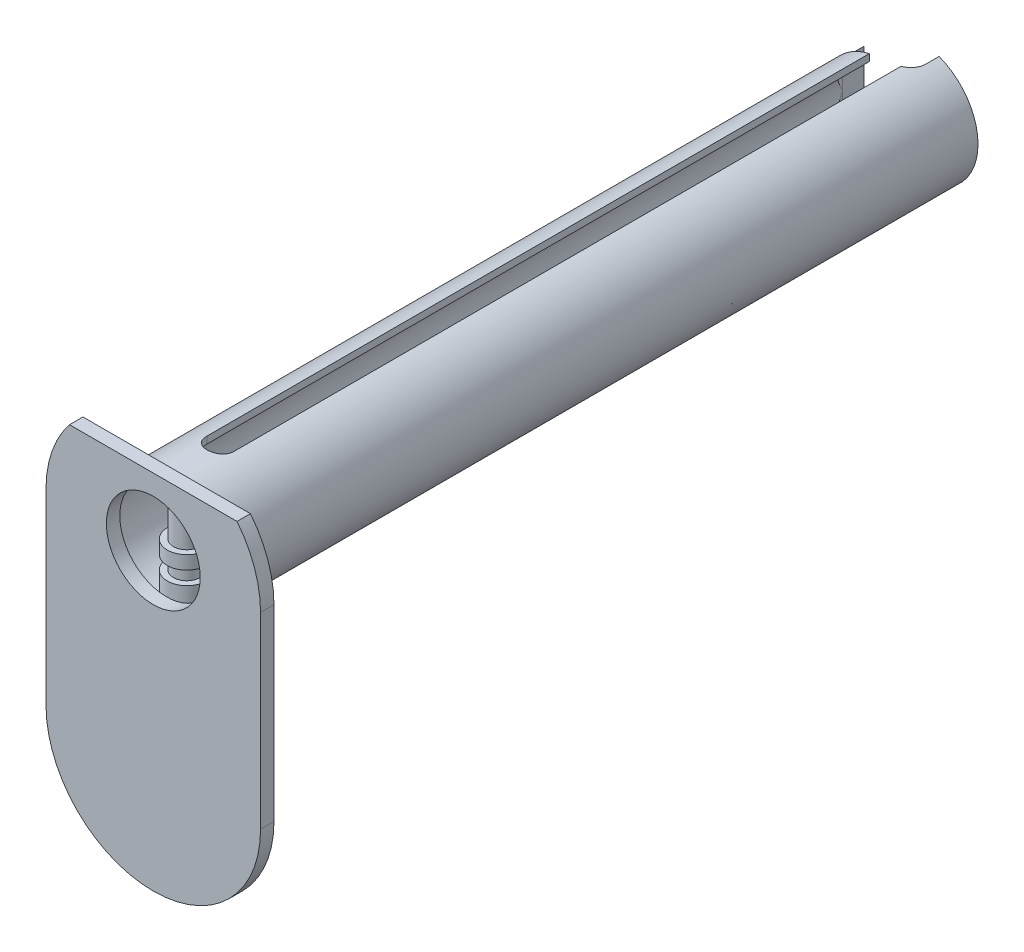
from build123d import *

# Parameters (mm, degrees)
ESQUISSE1_R                    = 4.5
ESQUISSE1_R_2                  = 4
BOSS_EXTRU_1_DEPTH             = 28
BOSS_EXTRU_2_REACH             = 6.5
ESQUISSE2_R                    = 1
ESQUISSE2_R_2                  = 0.5
BOSS_EXTRU_2_DIRECTION_2_REACH = 6.5
ENL_V_MAT_EXTRU_1_DEPTH        = 5.5
ENL_V_MAT_EXTRU_1_DEPTH_BACK   = 5.5
ESQUISSE4_R                    = 3.5
BOSS_EXTRU_3_DEPTH             = 1
ESQUISSE6_OUTSIDE_W            = 31.274
ESQUISSE6_OUTSIDE_H            = 45.274
ESQUISSE6_OUTSIDE_W_2          = 16
ESQUISSE6_OUTSIDE_H_2          = 27
ENL_V_MAT_EXTRU_2_DEPTH        = 58.0000001
BOSS_EXTRU_6_START             = -1.5
ESQUISSE7_R                    = 1.45
BOSS_EXTRU_6_DEPTH             = 1
BOSS_EXTRU_7_REACH             = 23.5
BOSS_EXTRU_7_START             = 1
ESQUISSE8_R                    = 1.45
ENL_V_MAT_EXTRU_3_DEPTH        = 6
ENL_V_MAT_EXTRU_3_DEPTH_BACK   = 23


with BuildPart() as part:
    # Esquisse1 → Boss.-Extru.1 (new body, symmetric)
    with BuildSketch(Plane.XY):
        Circle(ESQUISSE1_R)
        Circle(ESQUISSE1_R_2, mode=Mode.SUBTRACT)
    extrude(amount=BOSS_EXTRU_1_DEPTH, both=True)

    # Esquisse2 → Boss.-Extru.2 (add, up to next)
    with BuildSketch(Plane(origin=(0, 0, 0), x_dir=(1, 0, 0), z_dir=(0, 1, 0)), mode=Mode.PRIVATE) as boss_extru_2_sk1:
        with Locations((0, -26.5)):
            Circle(ESQUISSE2_R)
    boss_extru_2_tool1 = extrude(boss_extru_2_sk1.sketch, amount=BOSS_EXTRU_2_REACH, mode=Mode.PRIVATE) - part.part
    add(boss_extru_2_tool1.solids().sort_by_distance((0, 0, 26.5))[0])
    # Esquisse2 → Boss.-Extru.2 (add, up to next)
    with BuildSketch(Plane(origin=(0, 0, 0), x_dir=(1, 0, 0), z_dir=(0, 1, 0)), mode=Mode.PRIVATE) as boss_extru_2_sk2:
        with Locations((3, 26.5)):
            Circle(ESQUISSE2_R_2)
    boss_extru_2_tool2 = extrude(boss_extru_2_sk2.sketch, amount=BOSS_EXTRU_2_REACH, mode=Mode.PRIVATE) - part.part
    add(boss_extru_2_tool2.solids().sort_by_distance((3, 0, -26.5))[0])

    # Esquisse2 → Boss.-Extru.2 direction 2 (add, up to next)
    with BuildSketch(Plane(origin=(0, 0, 0), x_dir=(1, 0, 0), z_dir=(0, 1, 0)), mode=Mode.PRIVATE) as boss_extru_2_direction_2_sk1:
        with Locations((0, -26.5)):
            Circle(ESQUISSE2_R)
    boss_extru_2_direction_2_tool1 = extrude(boss_extru_2_direction_2_sk1.sketch, amount=-BOSS_EXTRU_2_DIRECTION_2_REACH, mode=Mode.PRIVATE) - part.part
    add(boss_extru_2_direction_2_tool1.solids().sort_by_distance((0, 0, 26.5))[0])
    # Esquisse2 → Boss.-Extru.2 direction 2 (add, up to next)
    with BuildSketch(Plane(origin=(0, 0, 0), x_dir=(1, 0, 0), z_dir=(0, 1, 0)), mode=Mode.PRIVATE) as boss_extru_2_direction_2_sk2:
        with Locations((3, 26.5)):
            Circle(ESQUISSE2_R_2)
    boss_extru_2_direction_2_tool2 = extrude(boss_extru_2_direction_2_sk2.sketch, amount=-BOSS_EXTRU_2_DIRECTION_2_REACH, mode=Mode.PRIVATE) - part.part
    add(boss_extru_2_direction_2_tool2.solids().sort_by_distance((3, 0, -26.5))[0])

    # Esquisse3 → Enlèv. mat.-Extru.1 (cut, two sides)
    with BuildSketch(Plane(origin=(0, 0, 0), x_dir=(1, 0, 0), z_dir=(0, 1, 0))) as enl_v_mat_extru_1_sk:
        with BuildLine():
            Line((1, 28), (1, -24))
            ThreePointArc((1, -24), (0, -25), (-1, -24))
            Line((-1, -24), (-1, 28))
            ThreePointArc((-1, 28), (0, 29), (1, 28))
        make_face()
    extrude(amount=ENL_V_MAT_EXTRU_1_DEPTH, mode=Mode.SUBTRACT)
    extrude(enl_v_mat_extru_1_sk.sketch, amount=-ENL_V_MAT_EXTRU_1_DEPTH_BACK, mode=Mode.SUBTRACT)

    # Esquisse4 → Boss.-Extru.3 (add)
    with BuildSketch(Plane.XY.offset(28)):
        with BuildLine():
            Line((8, 0), (8, -14))
            ThreePointArc((8, -14), (0, -22), (-8, -14))
            Line((-8, -14), (-8, 0))
            ThreePointArc((-8, 0), (0, 8), (8, 0))
        make_face()
        Circle(ESQUISSE4_R, mode=Mode.SUBTRACT)
    extrude(amount=BOSS_EXTRU_3_DEPTH)

    # Esquisse6 outside → Enlèv. mat.-Extru.2 (cut, through all)
    with BuildSketch(Plane.XY.offset(29)):
        with Locations((0, -7)):
            Rectangle(ESQUISSE6_OUTSIDE_W, ESQUISSE6_OUTSIDE_H)
        with Locations((0, -8.5)):
            Rectangle(ESQUISSE6_OUTSIDE_W_2, ESQUISSE6_OUTSIDE_H_2, mode=Mode.SUBTRACT)
    extrude(amount=-ENL_V_MAT_EXTRU_2_DEPTH, mode=Mode.SUBTRACT)

    # Esquisse7 → Boss.-Extru.6 (add)
    with BuildSketch(Plane(origin=(0, 0, 0), x_dir=(1, 0, 0), z_dir=(0, 1, 0)).offset(BOSS_EXTRU_6_START)):
        with Locations((0, -26.5)):
            Circle(ESQUISSE7_R)
    extrude(amount=BOSS_EXTRU_6_DEPTH)

    # Esquisse8 → Boss.-Extru.7 (add, up to next)
    with BuildSketch(Plane.XZ.offset(1.5).offset(BOSS_EXTRU_7_START), mode=Mode.PRIVATE) as boss_extru_7_sk1:
        with Locations((0, 26.5)):
            Circle(ESQUISSE8_R)
    boss_extru_7_tool1 = extrude(boss_extru_7_sk1.sketch, amount=BOSS_EXTRU_7_REACH, mode=Mode.PRIVATE) - part.part
    add(boss_extru_7_tool1.solids().sort_by_distance((0, -2.5, 26.5))[0])

    # Esquisse9 → Enlèv. mat.-Extru.3 (cut, two sides)
    with BuildSketch(Plane(origin=(0, 0, 0), x_dir=(1, 0, 0), z_dir=(0, 1, 0))) as enl_v_mat_extru_3_sk:
        with BuildLine():
            Line((0, 25.4), (-3, 25.4))
            ThreePointArc((-3, 25.4), (-3.707106781, 25.692893219), (-4, 26.4))
            Line((-4, 26.4), (-4, 28))
            Line((-4, 28), (1.6, 28))
            Line((1.6, 28), (1.6, 27))
            ThreePointArc((1.6, 27), (1.13137085, 25.86862915), (0, 25.4))
        make_face()
    extrude(amount=ENL_V_MAT_EXTRU_3_DEPTH, mode=Mode.SUBTRACT)
    extrude(enl_v_mat_extru_3_sk.sketch, amount=-ENL_V_MAT_EXTRU_3_DEPTH_BACK, mode=Mode.SUBTRACT)


solid = part.part
